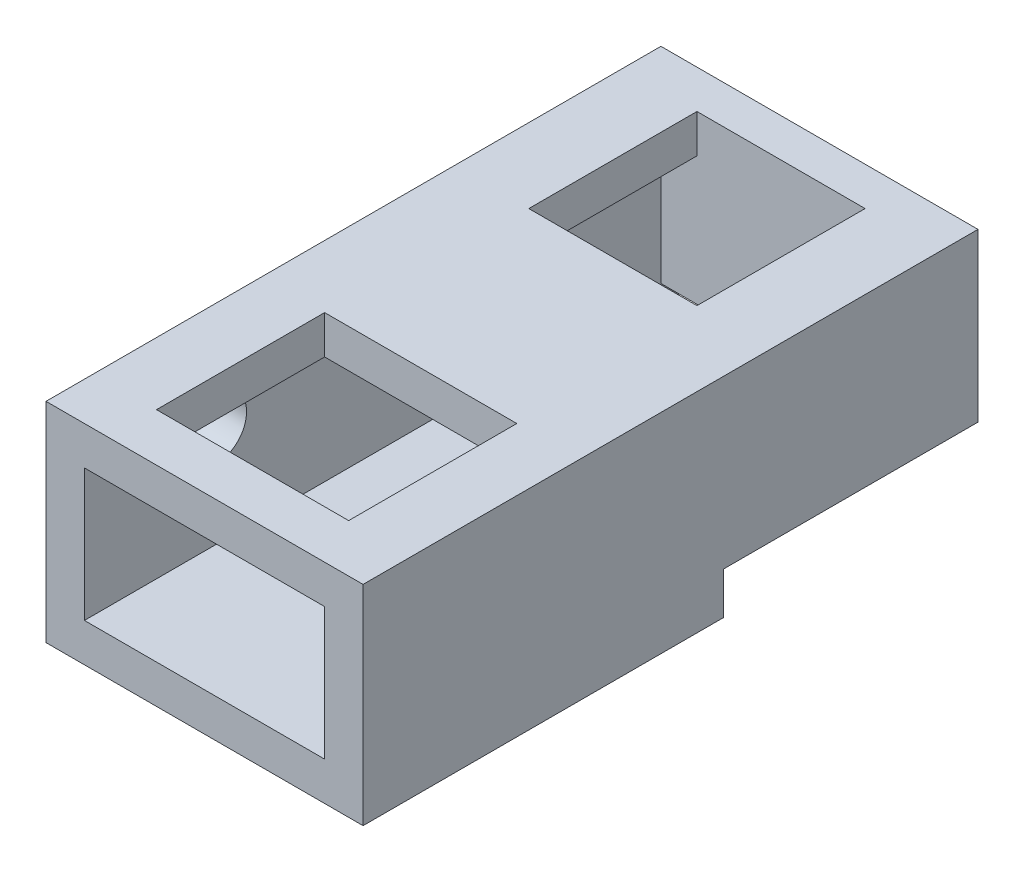
from build123d import *

# Parameters (mm, degrees)
SKETCH1_W           = 132
SKETCH1_H           = 87
SKETCH1_W_2         = 100
SKETCH1_H_2         = 55
BOSS_EXTRUDE1_DEPTH = 256
CUT_EXTRUDE1_REACH  = 89
SKETCH4_W           = 80
SKETCH4_H           = 70
CUT_EXTRUDE2_REACH  = 89
SKETCH5_W           = 70
SKETCH5_H           = 70
SKETCH6_W           = 100
SKETCH6_H           = 55
BOSS_EXTRUDE2_DEPTH = 16
SKETCH7_W           = 106
SKETCH7_H           = 17.5
CUT_EXTRUDE3_DEPTH  = 133
SKETCH9_W           = 106
SKETCH9_H           = 7.5
BOSS_EXTRUDE4_DEPTH = 16
CUT_EXTRUDE4_REACH  = 134
SKETCH10_R          = 12.5


with BuildPart() as part:
    # Sketch1 → Boss-Extrude1 (new body)
    with BuildSketch(Plane.XY):
        with Locations((-66, 43.5)):
            Rectangle(SKETCH1_W, SKETCH1_H)
        with Locations((-66, 43.5)):
            Rectangle(SKETCH1_W_2, SKETCH1_H_2, mode=Mode.SUBTRACT)
    extrude(amount=BOSS_EXTRUDE1_DEPTH)

    # Sketch4 → Cut-Extrude1 (cut, up to next)
    with BuildSketch(Plane(origin=(0, 87, 0), x_dir=(1, 0, 0), z_dir=(0, 1, 0)), mode=Mode.PRIVATE) as cut_extrude1_sk1:
        with Locations((-66, -201)):
            Rectangle(SKETCH4_W, SKETCH4_H)
    cut_extrude1_tool1 = extrude(cut_extrude1_sk1.sketch, amount=-CUT_EXTRUDE1_REACH, mode=Mode.PRIVATE) & part.part
    add(cut_extrude1_tool1.solids().sort_by_distance((-66, 87, 201))[0], mode=Mode.SUBTRACT)

    # Sketch5 → Cut-Extrude2 (cut, up to next)
    with BuildSketch(Plane(origin=(0, 87, 0), x_dir=(1, 0, 0), z_dir=(0, 1, 0)), mode=Mode.PRIVATE) as cut_extrude2_sk1:
        with Locations((-66, -51)):
            Rectangle(SKETCH5_W, SKETCH5_H)
    cut_extrude2_tool1 = extrude(cut_extrude2_sk1.sketch, amount=-CUT_EXTRUDE2_REACH, mode=Mode.PRIVATE) & part.part
    add(cut_extrude2_tool1.solids().sort_by_distance((-66, 87, 51))[0], mode=Mode.SUBTRACT)

    # Sketch6 → Boss-Extrude2 (add)
    with BuildSketch(Plane(origin=(0, 0, 0), x_dir=(-1, 0, 0), z_dir=(0, 0, -1))):
        with Locations((66, 43.5)):
            Rectangle(SKETCH6_W, SKETCH6_H)
    extrude(amount=-BOSS_EXTRUDE2_DEPTH)

    # Sketch7 → Cut-Extrude3 (cut, through all)
    with BuildSketch(Plane(origin=(0, 0, 0), x_dir=(0, 0, -1), z_dir=(1, 0, 0))):
        with Locations((-53, 8.75)):
            Rectangle(SKETCH7_W, SKETCH7_H)
    extrude(amount=-CUT_EXTRUDE3_DEPTH, mode=Mode.SUBTRACT)

    # Sketch9 → Boss-Extrude4 (add)
    with BuildSketch(Plane.ZY.offset(132)):
        with Locations((53, 13.75)):
            Rectangle(SKETCH9_W, SKETCH9_H)
    extrude(amount=-BOSS_EXTRUDE4_DEPTH)

    # Sketch10 → Cut-Extrude4 (cut, up to next)
    with BuildSketch(Plane.ZY.offset(132), mode=Mode.PRIVATE) as cut_extrude4_sk1:
        with Locations((201, 57.5)):
            Circle(SKETCH10_R)
    cut_extrude4_tool1 = extrude(cut_extrude4_sk1.sketch, amount=-CUT_EXTRUDE4_REACH, mode=Mode.PRIVATE) & part.part
    add(cut_extrude4_tool1.solids().sort_by_distance((-132, 57.5, 201))[0], mode=Mode.SUBTRACT)


solid = part.part
